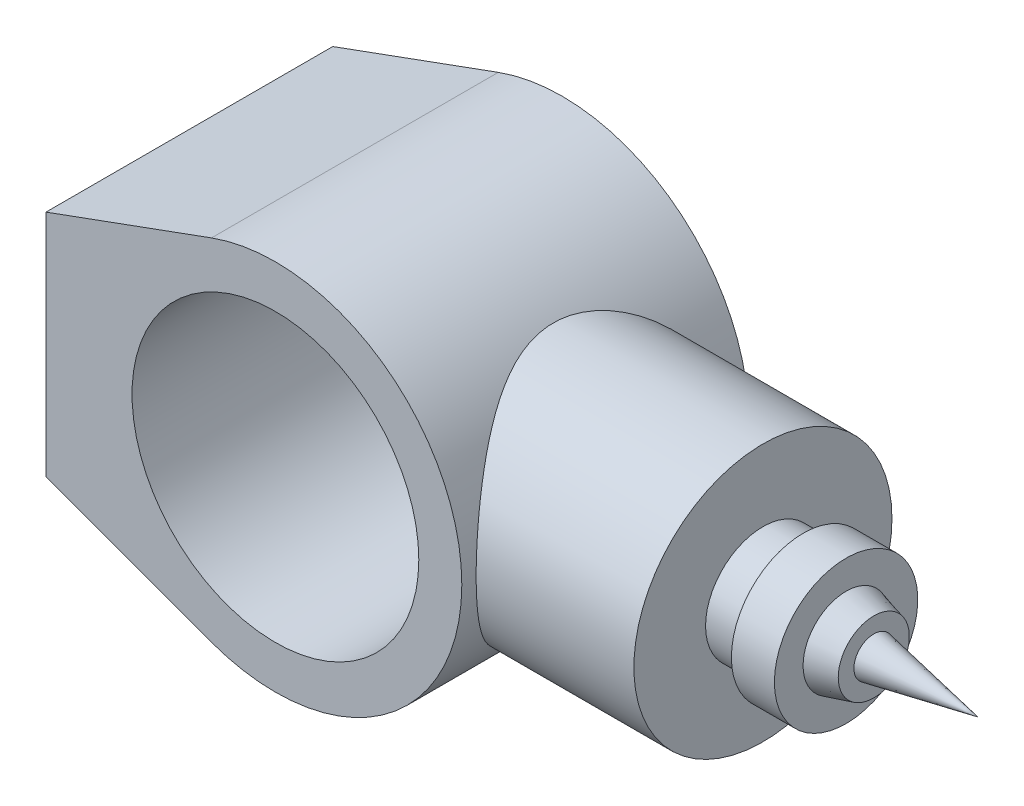
from build123d import *

# Parameters (mm, degrees)
SKETCH1_R           = 50
BOSS_EXTRUDE1_DEPTH = 50
BOSS_EXTRUDE2_REACH = 202
SKETCH2_R           = 45


with BuildPart() as part:
    # Sketch1 → Boss-Extrude1 (new body, symmetric)
    with BuildSketch(Plane.XY):
        with BuildLine():
            Line((-80, -40), (-80, 40))
            Line((-80, 40), (-22.281665693, 61.061668614))
            ThreePointArc((-22.281665693, 61.061668614), (65, 0), (-22.281665693, -61.061668614))
            Line((-22.281665693, -61.061668614), (-80, -40))
        make_face()
        Circle(SKETCH1_R, mode=Mode.SUBTRACT)
    extrude(amount=BOSS_EXTRUDE1_DEPTH, both=True)

    # Sketch2 → Boss-Extrude2 (add, up to next)
    with BuildSketch(Plane(origin=(120, 0, 0), x_dir=(0, 0, -1), z_dir=(1, 0, 0)), mode=Mode.PRIVATE) as boss_extrude2_sk1:
        Circle(SKETCH2_R)
    boss_extrude2_tool1 = extrude(boss_extrude2_sk1.sketch, amount=-BOSS_EXTRUDE2_REACH, mode=Mode.PRIVATE) - part.part
    add(boss_extrude2_tool1.solids().sort_by_distance((120, 0, 0))[0])

    # Sketch4 → Revolve1 (revolve)
    with BuildSketch(Plane.XY):
        Polygon((120, 0), (120, -20), (134, -20), (134, -25), (149, -25), (149, -15), (158.653629462, -12.390893217), (158.653629462, -6.923969146), (195, 0), align=None)
    revolve(axis=Axis((0, 0, 0), (1, 0, 0)))


solid = part.part
